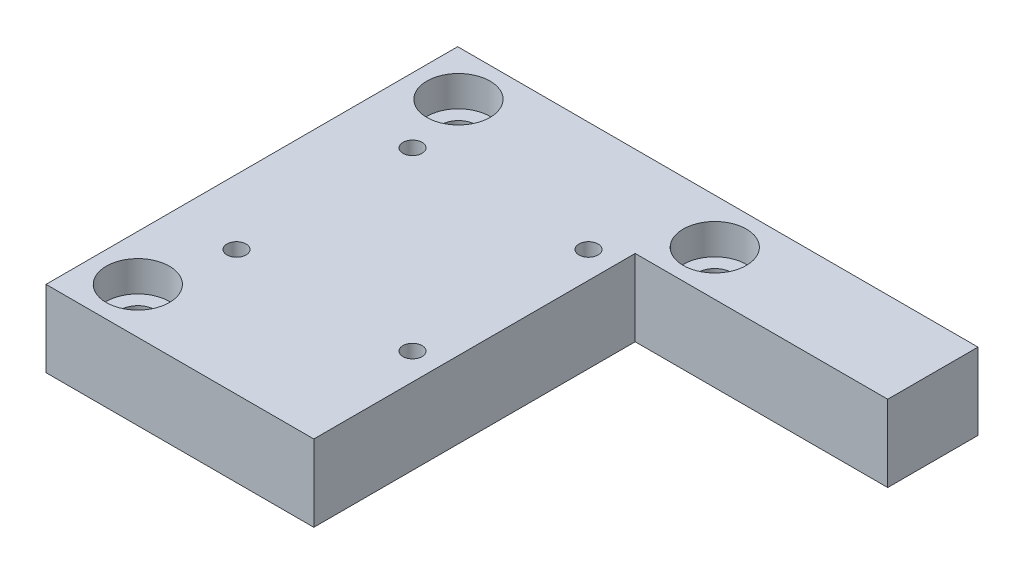
from build123d import *

# Parameters (mm, degrees)
SKETCH1_W                                           = 68
SKETCH1_H                                           = 53.8
BOSS_EXTRUDE1_DEPTH                                 = 10
SKETCH2_W                                           = 33
SKETCH2_H                                           = 42
CUT_EXTRUDE1_DEPTH                                  = 11
F_2_CLEARANCE_HOLE1_D                               = 2.5
F_2_CLEARANCE_HOLE1_DEPTH                           = 10
CBORE_FOR_8_BINDING_HEAD_MACHINE_SCREW1_D           = 4.5
CBORE_FOR_8_BINDING_HEAD_MACHINE_SCREW1_DEPTH       = 10
CBORE_FOR_8_BINDING_HEAD_MACHINE_SCREW1_CBORE_D     = 8.25
CBORE_FOR_8_BINDING_HEAD_MACHINE_SCREW1_CBORE_DEPTH = 4


with BuildPart() as part:
    # Sketch1 → Boss-Extrude1 (new body)
    with BuildSketch(Plane(origin=(0, 0, 0), x_dir=(1, 0, 0), z_dir=(0, 1, 0))):
        with Locations((34, -26.9)):
            Rectangle(SKETCH1_W, SKETCH1_H)
    extrude(amount=-BOSS_EXTRUDE1_DEPTH)

    # Sketch2 → Cut-Extrude1 (cut, through all)
    with BuildSketch(Plane.XZ.offset(10)):
        with Locations((51.5, 32.8)):
            Rectangle(SKETCH2_W, SKETCH2_H)
    extrude(amount=-CUT_EXTRUDE1_DEPTH, mode=Mode.SUBTRACT)

    # #2 Clearance Hole1
    with Locations(Plane(origin=(0, -10, 0), x_dir=(-1, 0, 0), z_dir=(0, -1, 0))):
        with Locations((-31.502183488, -14.402425), (-31.5, -37.404608488), (-8.497816512, -37.402425), (-8.5, -14.400241512)):
            Hole(F_2_CLEARANCE_HOLE1_D / 2, depth=F_2_CLEARANCE_HOLE1_DEPTH)

    # CBORE for #8 Binding Head Machine Screw1
    with Locations(Plane(origin=(0, 0, 0), x_dir=(1, 0, 0), z_dir=(0, 1, 0))):
        with Locations((6, -47.8), (6, -5.9), (39.5, -5.9)):
            CounterBoreHole(CBORE_FOR_8_BINDING_HEAD_MACHINE_SCREW1_D / 2, CBORE_FOR_8_BINDING_HEAD_MACHINE_SCREW1_CBORE_D / 2, CBORE_FOR_8_BINDING_HEAD_MACHINE_SCREW1_CBORE_DEPTH, depth=CBORE_FOR_8_BINDING_HEAD_MACHINE_SCREW1_DEPTH)


solid = part.part
